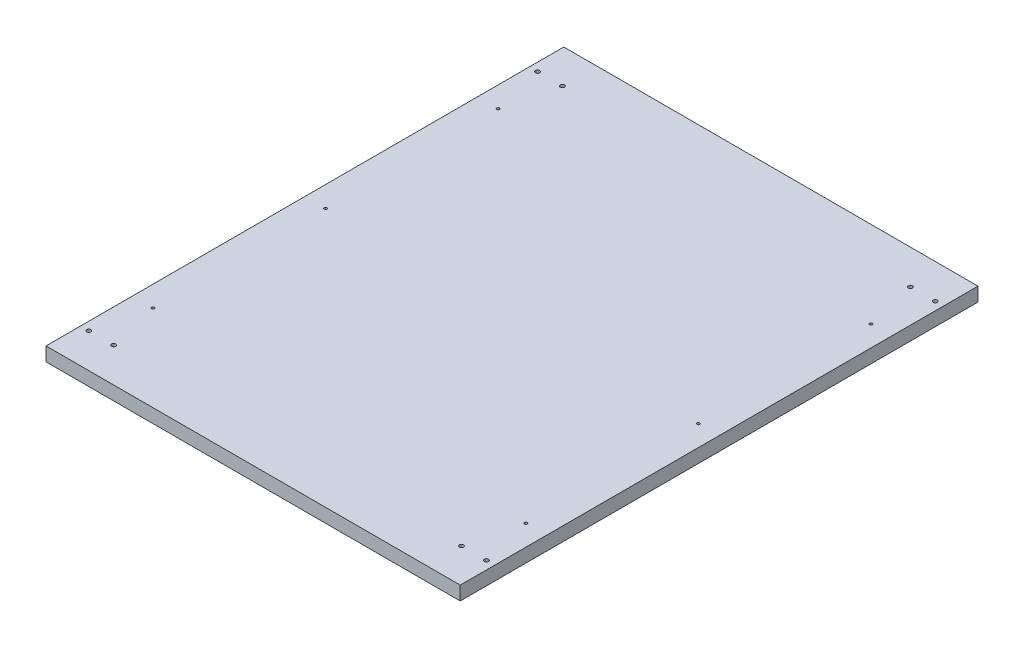
from build123d import *

# Parameters (mm, degrees)
SKETCH1_W           = 600
SKETCH1_H           = 750
BOSS_EXTRUDE1_DEPTH = 20
SKETCH5_R           = 3
CUT_EXTRUDE3_DEPTH  = 21
SKETCH6_R           = 2
CUT_EXTRUDE4_DEPTH  = 21


with BuildPart() as part:
    # Sketch1 → Boss-Extrude1 (new body)
    with BuildSketch(Plane(origin=(0, 0, 0), x_dir=(1, 0, 0), z_dir=(0, 1, 0))):
        with Locations((300, 375)):
            Rectangle(SKETCH1_W, SKETCH1_H)
    extrude(amount=BOSS_EXTRUDE1_DEPTH)

    # Sketch5 → Cut-Extrude3 (cut, through all)
    with BuildSketch(Plane(origin=(0, 20, 0), x_dir=(1, 0, 0), z_dir=(0, 1, 0))):
        with Locations((48, 50)):
            Circle(SKETCH5_R)
        with Locations((12, 50)):
            Circle(SKETCH5_R)
        with Locations((48, 700)):
            Circle(SKETCH5_R)
        with Locations((12, 700)):
            Circle(SKETCH5_R)
        with Locations((552, 50)):
            Circle(SKETCH5_R)
        with Locations((588, 50)):
            Circle(SKETCH5_R)
        with Locations((552, 700)):
            Circle(SKETCH5_R)
        with Locations((588, 700)):
            Circle(SKETCH5_R)
    extrude(amount=-CUT_EXTRUDE3_DEPTH, mode=Mode.SUBTRACT)

    # Sketch6 → Cut-Extrude4 (cut, through all)
    with BuildSketch(Plane(origin=(0, 20, 0), x_dir=(1, 0, 0), z_dir=(0, 1, 0))):
        with Locations((30, 625)):
            Circle(SKETCH6_R)
        with Locations((570, 625)):
            Circle(SKETCH6_R)
        with Locations((570, 375)):
            Circle(SKETCH6_R)
        with Locations((30, 375)):
            Circle(SKETCH6_R)
        with Locations((30, 125)):
            Circle(SKETCH6_R)
        with Locations((570, 125)):
            Circle(SKETCH6_R)
    extrude(amount=-CUT_EXTRUDE4_DEPTH, mode=Mode.SUBTRACT)


solid = part.part
